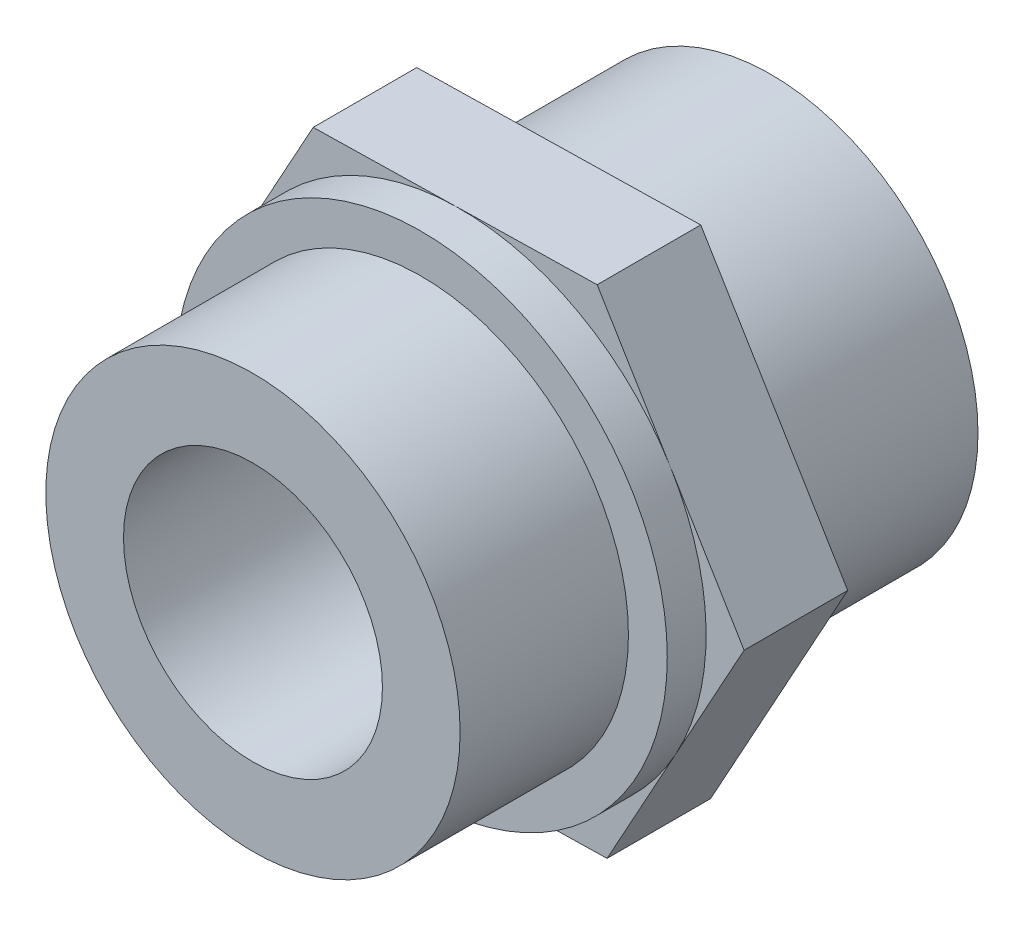
from build123d import *

# Parameters (mm, degrees)
BOSS_EXTRUDE1_DEPTH = 4
SKETCH2_R           = 8
BOSS_EXTRUDE3_DEPTH = 8
SKETCH3_R           = 5
CUT_EXTRUDE2_DEPTH  = 12
SKETCH4_R           = 5
CUT_EXTRUDE3_DEPTH  = 12
SKETCH6_R           = 9.5
BOSS_EXTRUDE6_DEPTH = 1.5
SKETCH15_R          = 5
CUT_EXTRUDE8_DEPTH  = 3.5


with BuildPart() as part:
    # Sketch1 → Boss-Extrude1 (new body)
    with BuildSketch(Plane.XY):
        Polygon((5.675106298, -9.387571669), (10.967428694, 0.221000389), (5.292322396, 9.608572058), (-5.675106298, 9.387571669), (-10.967428694, -0.221000389), (-5.292322396, -9.608572058), align=None)
    boss_extrude1 = extrude(amount=BOSS_EXTRUDE1_DEPTH)

    # Sketch2 → Boss-Extrude3 (add)
    with BuildSketch(Plane.XY.offset(4)):
        Circle(SKETCH2_R)
    boss_extrude3 = extrude(amount=BOSS_EXTRUDE3_DEPTH)

    # Sketch3 → Cut-Extrude2 (cut)
    with BuildSketch(Plane.XY.offset(12)):
        Circle(SKETCH3_R)
    extrude(amount=-CUT_EXTRUDE2_DEPTH, mode=Mode.SUBTRACT)

    # Mirror2: Boss-Extrude1, Boss-Extrude3 across plane
    add(boss_extrude1.mirror(Plane(origin=(0, 0, 2), x_dir=(1, 0, 0), z_dir=(0, 0, -1))))
    add(boss_extrude3.mirror(Plane(origin=(0, 0, 2), x_dir=(1, 0, 0), z_dir=(0, 0, -1))))

    # Sketch4 → Cut-Extrude3 (cut)
    with BuildSketch(Plane(origin=(0, 0, -8), x_dir=(-1, 0, 0), z_dir=(0, 0, -1))):
        Circle(SKETCH4_R)
    extrude(amount=-CUT_EXTRUDE3_DEPTH, mode=Mode.SUBTRACT)

    # Sketch6 → Boss-Extrude6 (add)
    with BuildSketch(Plane.XY.offset(4)):
        Circle(SKETCH6_R)
    extrude(amount=BOSS_EXTRUDE6_DEPTH)

    # Sketch15 → Cut-Extrude8 (cut)
    with BuildSketch(Plane.XY.offset(4)):
        Circle(SKETCH15_R)
    extrude(amount=CUT_EXTRUDE8_DEPTH, mode=Mode.SUBTRACT)


solid = part.part
